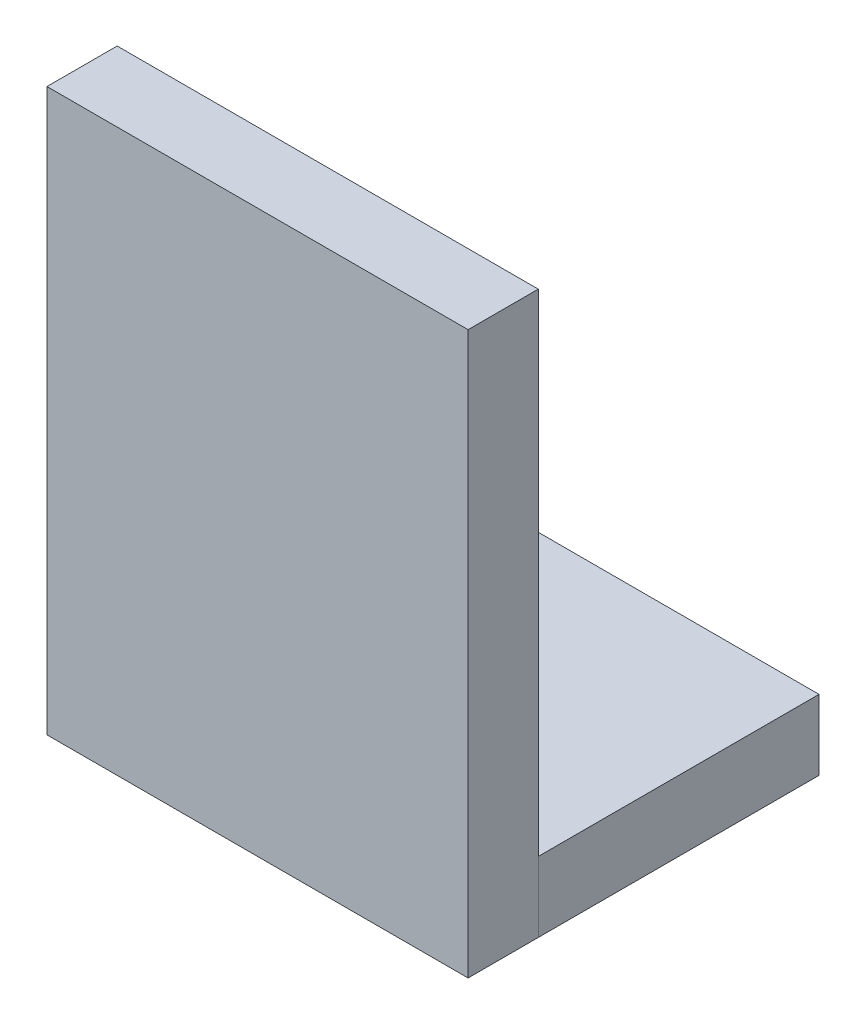
from build123d import *

# Parameters (mm, degrees)
SKETCH1_W           = 7.62
SKETCH1_H           = 5.08
BOSS_EXTRUDE1_DEPTH = 1.27
SKETCH2_W           = 7.62
SKETCH2_H           = 10.16
BOSS_EXTRUDE2_DEPTH = 1.27


with BuildPart() as part:
    # Sketch1 → Boss-Extrude1 (new body)
    with BuildSketch(Plane(origin=(0, 0, 0), x_dir=(1, 0, 0), z_dir=(0, 1, 0))):
        with Locations((3.81, -2.54)):
            Rectangle(SKETCH1_W, SKETCH1_H)
    extrude(amount=BOSS_EXTRUDE1_DEPTH)


with BuildPart() as body_2:
    # Sketch2 → Boss-Extrude2 (new body)
    with BuildSketch(Plane.XY.offset(5.08)):
        with Locations((3.81, 5.08)):
            Rectangle(SKETCH2_W, SKETCH2_H)
    extrude(amount=BOSS_EXTRUDE2_DEPTH)


solid = Compound([part.part, body_2.part])
